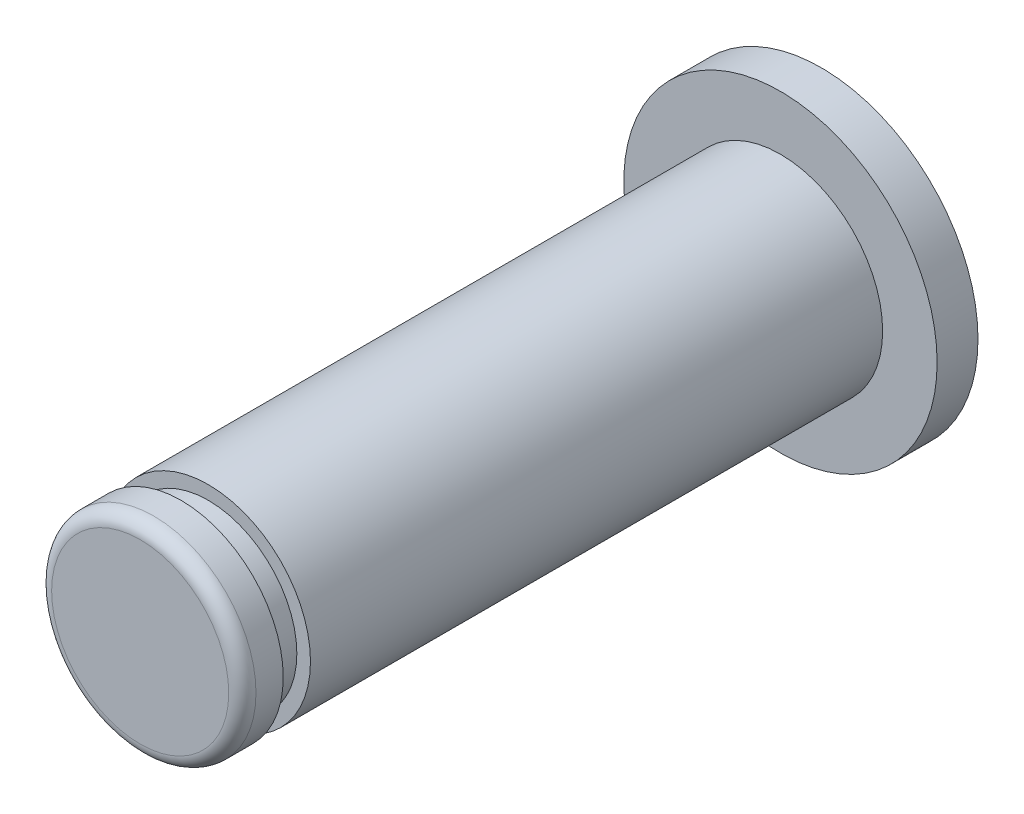
from build123d import *

# Parameters (mm, degrees)
ESQUISSE1_R        = 7.5
BOSS_EXTRU_1_DEPTH = 45
ESQUISSE2_R        = 11.5
BOSS_EXTRU_2_DEPTH = 3
BOSS_EXTRU_3_START = 45
ESQUISSE3_R        = 6.5
BOSS_EXTRU_3_DEPTH = 2
BOSS_EXTRU_4_START = 47
ESQUISSE4_R        = 7.5
BOSS_EXTRU_4_DEPTH = 3
CONG_1_R           = 1


with BuildPart() as part:
    # Esquisse1 → Boss.-Extru.1 (new body)
    with BuildSketch(Plane.XY):
        Circle(ESQUISSE1_R)
    extrude(amount=BOSS_EXTRU_1_DEPTH)

    # Esquisse2 → Boss.-Extru.2 (add)
    with BuildSketch(Plane.XY):
        Circle(ESQUISSE2_R)
    extrude(amount=BOSS_EXTRU_2_DEPTH)

    # Esquisse3 → Boss.-Extru.3 (add)
    with BuildSketch(Plane.XY.offset(BOSS_EXTRU_3_START)):
        Circle(ESQUISSE3_R)
    extrude(amount=BOSS_EXTRU_3_DEPTH)

    # Esquisse4 → Boss.-Extru.4 (add)
    with BuildSketch(Plane.XY.offset(BOSS_EXTRU_4_START)):
        Circle(ESQUISSE4_R)
    extrude(amount=BOSS_EXTRU_4_DEPTH)

    # Congé1
    cong_1_edges = [part.edges().sort_by_distance(p)[0] for p in [
        (-7.5, 0, 50),
    ]]
    fillet(cong_1_edges, radius=CONG_1_R)


solid = part.part
